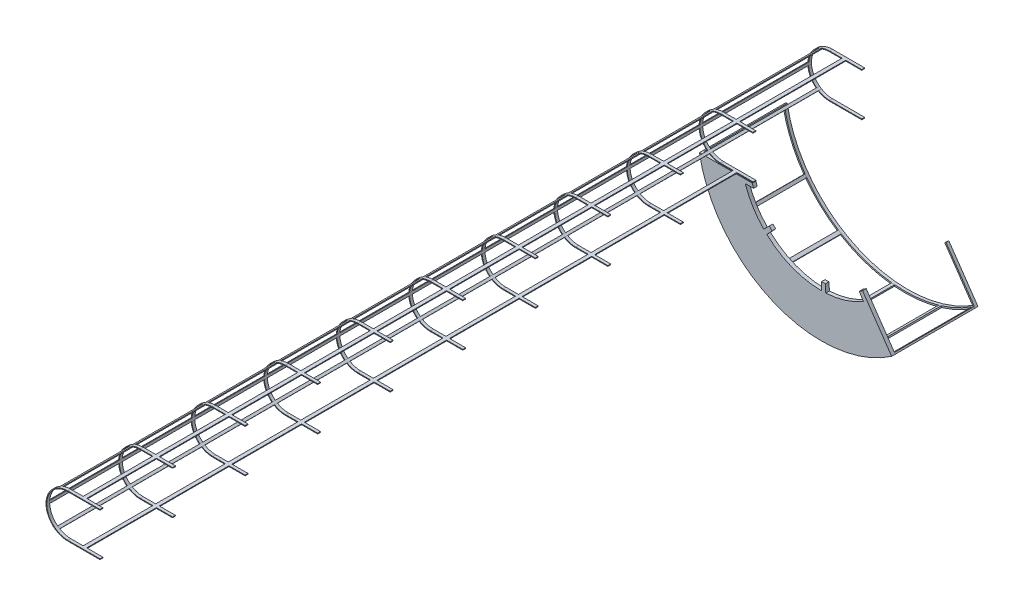
from build123d import *

# Parameters (mm, degrees)
EXTRUDE1_DEPTH      = 50
EXTRUDE2_DEPTH      = 40
SKETCH4_W           = 49.886608622
SKETCH4_H           = 10
EXTRUDE3_DEPTH      = 1500
EXTRUDE3_DEPTH_BACK = 9000
LPATTERN1_COUNT     = 9
LPATTERN1_PITCH     = 1000
LPATTERN2_COUNT     = 2
LPATTERN2_PITCH     = 1500
CUT_EXTRUDE1_REACH  = 602
SKETCH5_W           = 54.529877967
SKETCH5_H           = 1460
EXTRUDE4_DEPTH      = 1100
EXTRUDE5_DEPTH      = 40
LPATTERN3_COUNT     = 2
LPATTERN3_PITCH     = 9000


with BuildPart() as part:
    # Sketch2 → Extrude1 (new body)
    with BuildSketch(Plane.XY):
        with BuildLine():
            Line((1635.833007494, 3341.46133228), (908.358346912, 3341.46133228))
            ThreePointArc((908.358346912, 3341.46133228), (1931.211746202, 2065.564542423), (3557.764796577, 2234.285818867))
            Line((3557.764796577, 2234.285818867), (3217.714067866, 2728.619210317))
            Line((3217.714067866, 2728.619210317), (3156.523423429, 2817.572346528))
            ThreePointArc((3156.523423429, 2817.572346528), (3134.007510308, 2802.528714775), (3111.092521849, 2788.100253182))
            Line((3111.092521849, 2788.100253182), (3167.378110816, 2695.965092234))
            ThreePointArc((3167.378110816, 2695.965092234), (2918.562610741, 2583.402454182), (2649.772208911, 2535.11974043))
            Line((2649.772208911, 2535.11974043), (2643.925427695, 2642.928694408))
            ThreePointArc((2643.925427695, 2642.928694408), (2616.85875657, 2641.828240122), (2589.772208911, 2641.46133228))
            Line((2589.772208911, 2641.46133228), (2589.772208911, 2533.493951056))
            ThreePointArc((2589.772208911, 2533.493951056), (2185.316890533, 2609.953885243), (1836.683841924, 2828.780811186))
            Line((1836.683841924, 2828.780811186), (1910.069557236, 2907.97356462))
            ThreePointArc((1910.069557236, 2907.97356462), (1890.458400686, 2926.646532751), (1871.360035008, 2945.843658275))
            Line((1871.360035008, 2945.843658275), (1793.794953952, 2870.73963968))
            ThreePointArc((1793.794953952, 2870.73963968), (1643.595335166, 3064.97105357), (1539.861490232, 3287.513312569))
            Line((1539.861490232, 3287.513312569), (1654.507113154, 3287.513312569))
            Line((1654.507113154, 3287.513312569), (1635.833007494, 3341.46133228))
        make_face()
    extrude(amount=EXTRUDE1_DEPTH)

    # Sketch3 → Extrude2 (add)
    with BuildSketch(Plane(origin=(0, 0, 0), x_dir=(-1, 0, 0), z_dir=(0, 0, -1))):
        with BuildLine():
            Line((-1635.833007494, 3341.46133228), (-1192.331620174, 3341.46133228))
            ThreePointArc((-1192.331620174, 3341.46133228), (-892.331620174, 3641.46133228), (-1192.331620174, 3941.46133228))
            Line((-1192.331620174, 3941.46133228), (-1635.833007494, 3941.46133228))
            Line((-1635.833007494, 3941.46133228), (-1635.833007494, 3931.46133228))
            Line((-1635.833007494, 3931.46133228), (-1192.331620174, 3931.46133228))
            ThreePointArc((-1192.331620174, 3931.46133228), (-902.331620174, 3641.46133228), (-1192.331620174, 3351.46133228))
            Line((-1192.331620174, 3351.46133228), (-1635.833007494, 3351.46133228))
            Line((-1635.833007494, 3351.46133228), (-1635.833007494, 3341.46133228))
        make_face()
    extrude2 = extrude(amount=-EXTRUDE2_DEPTH)

    # Sketch4 → Extrude3 (add, two sides)
    with BuildSketch(Plane(origin=(0, 0, 0), x_dir=(-1, 0, 0), z_dir=(0, 0, -1))) as extrude3_sk:
        with Locations((-1389.139009523, 3936.46133228)):
            Rectangle(SKETCH4_W, SKETCH4_H)
        Polygon((-1084.885873907, 3921.560264104), (-1051.639512443, 3906.424972846), (-1055.790796057, 3897.306213701), (-1089.037157521, 3912.441504959), align=None)
        Polygon((-893.14932028, 3663.596178791), (-892.817354868, 3624.396606138), (-902.839148193, 3624.311735602), (-903.171113604, 3663.511308254), align=None)
        Polygon((-1013.388612807, 3413.252217399), (-1041.563004314, 3393.734013496), (-1035.858733011, 3385.499937567), (-1007.684341505, 3405.01814147), align=None)
        with Locations((-1389.139009523, 3346.46133228)):
            Rectangle(SKETCH4_W, SKETCH4_H)
    extrude(amount=EXTRUDE3_DEPTH)
    extrude(extrude3_sk.sketch, amount=-EXTRUDE3_DEPTH_BACK)

    # LPattern1: Extrude2 ×9
    with Locations(*[(0, 0, i * LPATTERN1_PITCH) for i in range(1, LPATTERN1_COUNT)]):
        add(extrude2)

    # LPattern2: Extrude2 ×2
    with Locations(*[(0, 0, -i * LPATTERN2_PITCH) for i in range(1, LPATTERN2_COUNT)]):
        add(extrude2)

    # Sketch5 → Cut-Extrude1 (cut, up to next)
    with BuildSketch(Plane.XZ.offset(-3341.46133228), mode=Mode.PRIVATE) as cut_extrude1_sk1:
        with Locations((1386.817374851, -730)):
            Rectangle(SKETCH5_W, SKETCH5_H)
    cut_extrude1_tool1 = extrude(cut_extrude1_sk1.sketch, amount=-CUT_EXTRUDE1_REACH, mode=Mode.PRIVATE) & part.part
    add(cut_extrude1_tool1.solids().sort_by_distance((1386.817375, 3341.461332, -730))[0], mode=Mode.SUBTRACT)

    # Sketch6 → Extrude4 (add)
    with BuildSketch(Plane(origin=(0, 0, 0), x_dir=(-1, 0, 0), z_dir=(0, 0, -1))):
        Polygon((-908.358346912, 3341.46133228), (-915.988299524, 3301.46133228), (-935.634085713, 3305.208742721), (-928.004133101, 3345.208742721), align=None)
        Polygon((-1197.498848723, 2652.154774212), (-1221.0482916, 2619.821761049), (-1237.214798181, 2631.596482487), (-1213.665355305, 2663.92949565), align=None)
        Polygon((-1662.017142627, 2207.437932084), (-1702.017142627, 2182.337102609), (-1712.647811944, 2199.277848456), (-1672.647811944, 2224.378677931), align=None)
        Polygon((-2406.283837212, 1943.378709797), (-2446.099932845, 1939.54745302), (-2448.015561234, 1959.455500837), (-2408.1994656, 1963.286757614), align=None)
        Polygon((-3058.893977828, 1999.183237299), (-3097.224268686, 2010.619530523), (-3091.506122074, 2029.784675952), (-3053.175831216, 2018.348382728), align=None)
        Polygon((-3557.764796577, 2234.285818867), (-3524.546034345, 2212.003228448), (-3513.404739136, 2228.612609564), (-3546.623501368, 2250.895199983), align=None)
    extrude(amount=EXTRUDE4_DEPTH)

    # Sketch7 → Extrude5 (add)
    with BuildSketch(Plane(origin=(0, 0, -1100), x_dir=(-1, 0, 0), z_dir=(0, 0, -1))):
        with BuildLine():
            Line((-3557.764796577, 2234.285818867), (-3156.523423429, 2817.572346528))
            Line((-3156.523423429, 2817.572346528), (-3140.045643714, 2806.237322238))
            Line((-3140.045643714, 2806.237322238), (-3529.884838299, 2239.526196782))
            ThreePointArc((-3529.884838299, 2239.526196782), (-1929.70789614, 2087.901232676), (-928.047409835, 3344.974279931))
            Line((-928.047409835, 3344.974279931), (-908.358346912, 3341.46133228))
            ThreePointArc((-908.358346912, 3341.46133228), (-1931.211746202, 2065.564542423), (-3557.764796577, 2234.285818867))
        make_face()
    extrude(amount=EXTRUDE5_DEPTH)

    # LPattern3: Extrude2 ×2
    with Locations(*[(0, 0, i * LPATTERN3_PITCH) for i in range(1, LPATTERN3_COUNT)]):
        add(extrude2)


solid = part.part
